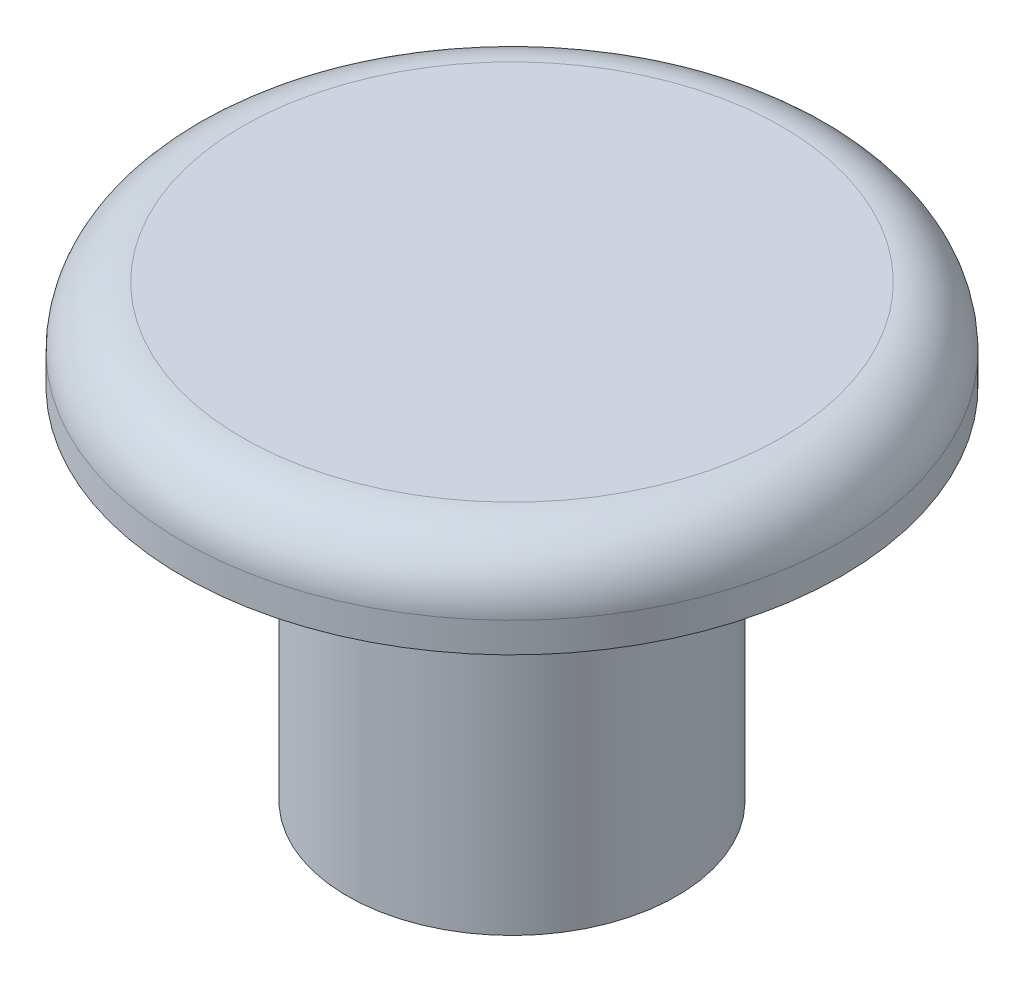
from build123d import *

# Parameters (mm, degrees)
FILLET2_R = 2


with BuildPart() as part:
    # Sketch1 → Revolve1 (revolve)
    with BuildSketch(Plane.XY):
        Polygon((0, 0), (5.5, 0), (5.5, 12), (11, 12), (11, 15), (0, 15), align=None)
    revolve(axis=Axis((0, 15, 0), (0, -1, 0)))

    # Fillet2
    fillet2_edges = [part.edges().sort_by_distance(p)[0] for p in [
        (-11, 15, 0),
    ]]
    fillet(fillet2_edges, radius=FILLET2_R)


solid = part.part
